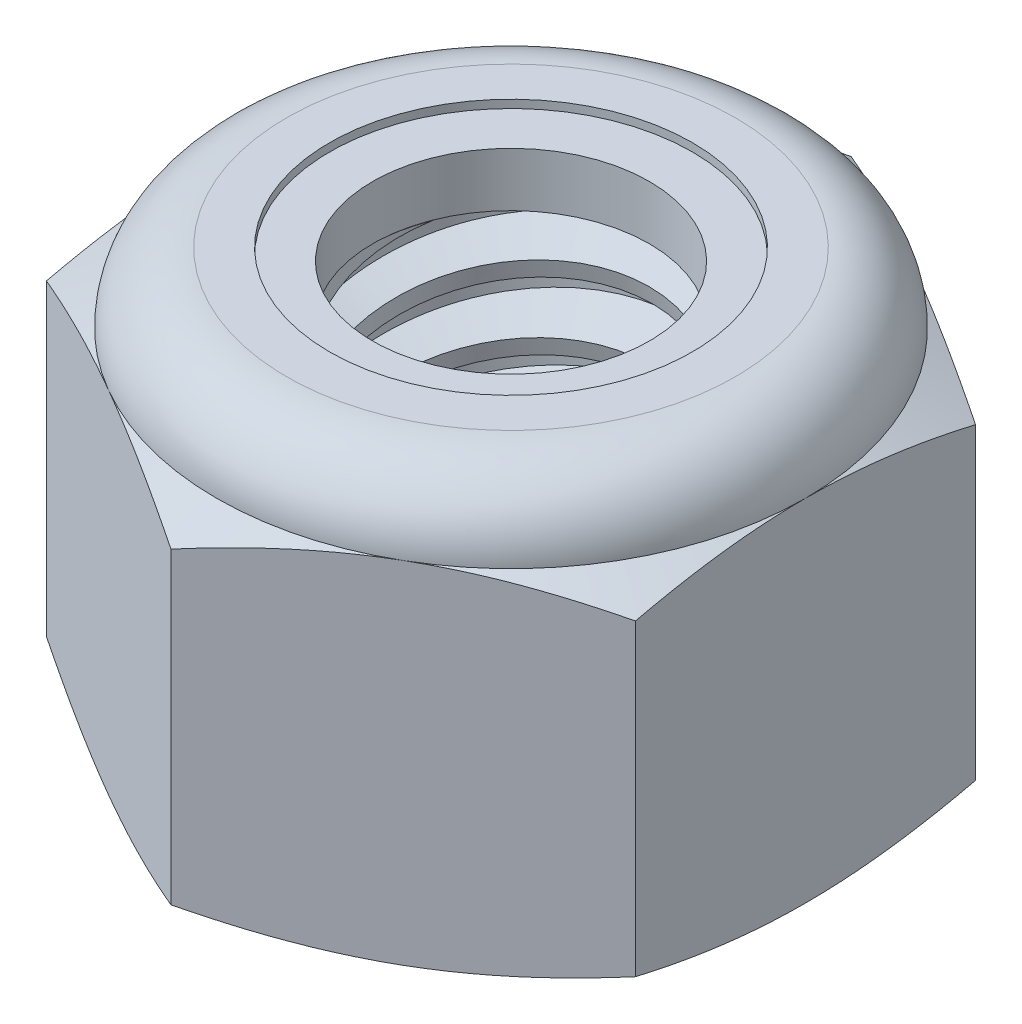
from build123d import *

# Parameters (mm, degrees)
EXTRUDE1_DEPTH      = 7.9375
SKETCH2_W           = 3.175
SKETCH2_H           = 7.9375
LPATTERN1_COUNT     = 6
LPATTERN1_PITCH     = 1.27
LPATTERN1_COL_COUNT = 2
LPATTERN1_COL_PITCH = 1.27


with BuildPart() as part:
    # Sketch1 → Extrude1 (new body)
    with BuildSketch(Plane(origin=(0, 0, 0), x_dir=(1, 0, 0), z_dir=(0, 1, 0))):
        Polygon((0, 6.415804866), (-5.55625, 3.207902433), (-5.55625, -3.207902433), (0, -6.415804866), (5.55625, -3.207902433), (5.55625, 3.207902433), align=None)
    extrude(amount=EXTRUDE1_DEPTH)

    # Sketch4 → Cut-Revolve2 (revolve, cut)
    with BuildSketch(Plane(origin=(0, 0, 0), x_dir=(0, 0, -1), z_dir=(1, 0, 0))):
        Polygon((0, 7.9375), (3.175, 7.9375), (2.609908356, 7.673993439), (2.609908356, 0.263506561), (3.175, 0), (0, 0), align=None)
    revolve(axis=Axis((0, 7.9375, 0), (0, 1, 0)), mode=Mode.SUBTRACT)


with BuildPart() as body_2:
    # Sketch2 → Revolve1 (revolve)
    with BuildSketch(Plane(origin=(0, 0, 0), x_dir=(0, 0, -1), z_dir=(1, 0, 0))):
        with Locations((1.5875, 3.96875)):
            Rectangle(SKETCH2_W, SKETCH2_H)
    revolve(axis=Axis((0, -3.175, 0), (0, 1, 0)))

    # Sketch3 → Cut-Revolve1 (revolve, cut)
    with BuildSketch(Plane(origin=(0, 0, 0), x_dir=(0, 0, -1), z_dir=(1, 0, 0))):
        Polygon((3.206133436, 7.781832818), (3.424067492, 6.692162542), (2.672175229, 6.946518763), (2.609908356, 7.257853128), align=None)
    cut_revolve1 = revolve(axis=Axis((0, 7.9375, 0.272704483), (0, -0.980580676, -0.196116135)), mode=Mode.SUBTRACT)

    # LPattern1: Cut-Revolve1 ×6
    with Locations(*[(0, -i * LPATTERN1_PITCH, 0) for i in range(1, LPATTERN1_COUNT)]):
        add(cut_revolve1, mode=Mode.SUBTRACT)

    # LPattern1 col: Cut-Revolve1 ×2
    with Locations(*[(0, i * LPATTERN1_COL_PITCH, 0) for i in range(1, LPATTERN1_COL_COUNT)]):
        add(cut_revolve1, mode=Mode.SUBTRACT)


with BuildPart() as part_1:
    add(part.part)

    # Combine1: cut body 2
    add(body_2.part, mode=Mode.SUBTRACT)

    # Sketch5 → Cut-Revolve3 (revolve, cut)
    with BuildSketch(Plane(origin=(0, 0, 0), x_dir=(0, 0, -1), z_dir=(1, 0, 0))):
        with BuildLine():
            Line((0, 0), (5.55625, 0))
            Line((5.55625, 0), (6.415804866, 0.400817017))
            Line((6.415804866, 0.400817017), (6.415804866, 6.213766317))
            Line((6.415804866, 6.213766317), (5.55625, 6.614583333))
            ThreePointArc((5.55625, 6.614583333), (5.168776679, 7.550026679), (4.233333333, 7.9375))
            Line((4.233333333, 7.9375), (4.233333333, 9.2075))
            Line((4.233333333, 9.2075), (7.685804866, 9.2075))
            Line((7.685804866, 9.2075), (7.685804866, -1.27))
            Line((7.685804866, -1.27), (0, -1.27))
            Line((0, -1.27), (0, 0))
        make_face()
    revolve(axis=Axis((0, 0, 0), (0, 1, 0)), mode=Mode.SUBTRACT)

    # Sketch6 → Cut-Revolve4 (revolve, cut)
    with BuildSketch(Plane(origin=(0, 0, 0), x_dir=(0, 0, -1), z_dir=(1, 0, 0))):
        with BuildLine():
            Line((0, 6.614583333), (5.40385, 6.614583333))
            ThreePointArc((5.40385, 6.614583333), (5.061013606, 7.442263606), (4.233333333, 7.7851))
            Line((4.233333333, 7.7851), (3.421620845, 7.7851))
            Line((3.421620845, 7.7851), (3.421620845, 9.2075))
            Line((3.421620845, 9.2075), (0, 9.2075))
            Line((0, 9.2075), (0, 6.614583333))
        make_face()
    revolve(axis=Axis((0, 9.2075, 0), (0, 1, 0)), mode=Mode.SUBTRACT)


with BuildPart() as body_2_2:
    # Sketch7 → Revolve2 (revolve)
    with BuildSketch(Plane(origin=(0, 0, 0), x_dir=(0, 0, -1), z_dir=(1, 0, 0))):
        with BuildLine():
            Line((2.609908356, 6.690783333), (5.324993778, 6.690783333))
            ThreePointArc((5.324993778, 6.690783333), (4.979705237, 7.4148695), (4.233333333, 7.7089))
            Line((4.233333333, 7.7089), (2.609908356, 7.7089))
            Line((2.609908356, 7.7089), (2.609908356, 6.690783333))
        make_face()
    revolve(axis=Axis((0, 6.690783333, 0), (0, 1, 0)))


solid = Compound([part_1.part, body_2_2.part])
